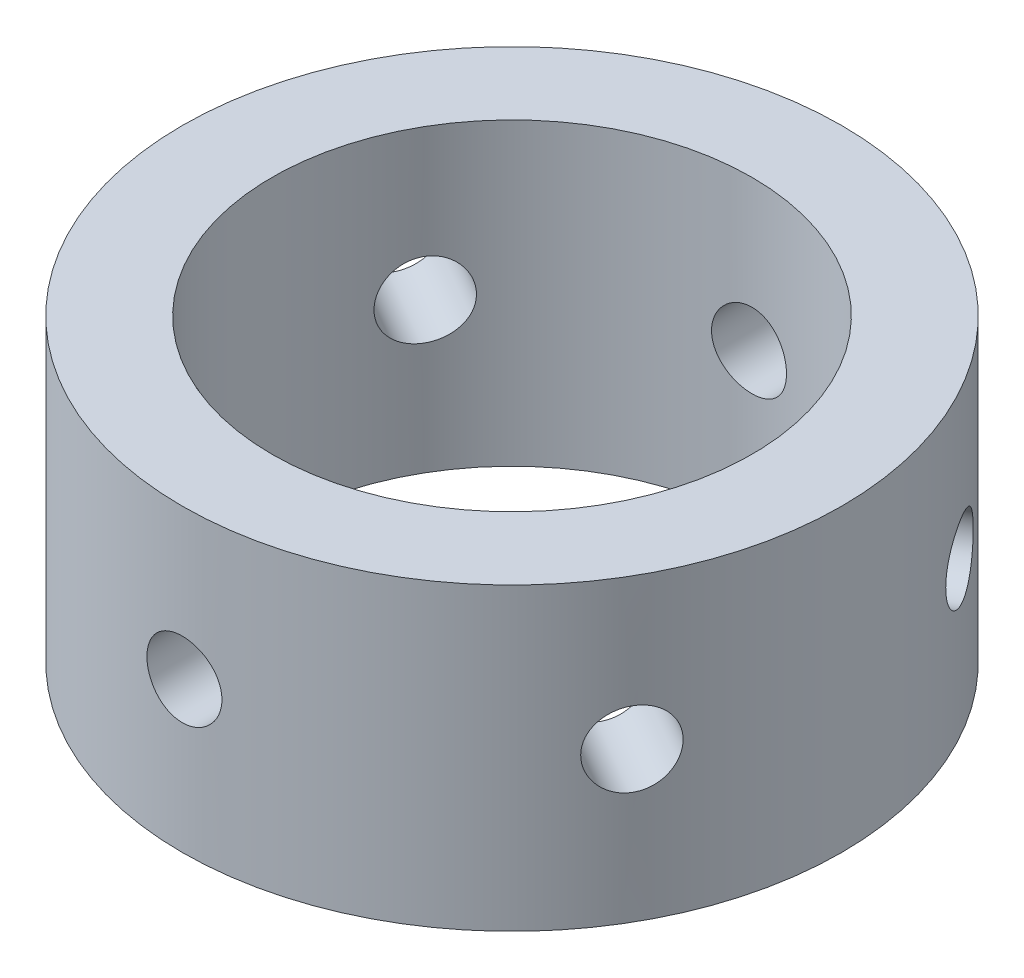
from build123d import *

# Parameters (mm, degrees)
SKETCH1_R                        = 34.8996
SKETCH1_R_2                      = 25.4
BOSS_EXTRUDE1_DEPTH              = 31.75
TAP_DRILL_FOR_3_8_16_TAP1_REACH  = 86.249
TAP_DRILL_FOR_3_8_16_TAP1_BORE_R = 3.96875
CIRPATTERN2_COUNT                = 6


with BuildPart() as part:
    # Sketch1 → Boss-Extrude1 (new body)
    with BuildSketch(Plane(origin=(0, 0, 0), x_dir=(1, 0, 0), z_dir=(0, 1, 0))):
        with Locations(Location((0, 0, 0), (0, 0, 270))):
            Circle(SKETCH1_R)
        with Locations(Location((0, 0, 0), (0, 0, 270))):
            Circle(SKETCH1_R_2, mode=Mode.SUBTRACT)
    extrude(amount=BOSS_EXTRUDE1_DEPTH)

    # Tap Drill for 3/8-16 Tap1 bore → Tap Drill for 3/8-16 Tap1 (cut, up to next)
    with BuildSketch(Plane.XY.offset(34.8996), mode=Mode.PRIVATE) as tap_drill_for_3_8_16_tap1_sk1:
        with Locations((0, 15.875)):
            Circle(TAP_DRILL_FOR_3_8_16_TAP1_BORE_R)
    tap_drill_for_3_8_16_tap1_tool1 = extrude(tap_drill_for_3_8_16_tap1_sk1.sketch, amount=-TAP_DRILL_FOR_3_8_16_TAP1_REACH, mode=Mode.PRIVATE) & part.part
    tap_drill_for_3_8_16_tap1 = tap_drill_for_3_8_16_tap1_tool1.solids().sort_by_distance((0, 15.875, 34.8996))[0]
    add(tap_drill_for_3_8_16_tap1, mode=Mode.SUBTRACT)

    # CirPattern2: Tap Drill for 3/8-16 Tap1 ×6 about axis
    cirpattern2_axis = Axis((0, 31.75, 0), (0, -1, 0))
    for i in range(1, CIRPATTERN2_COUNT):
        add(tap_drill_for_3_8_16_tap1.rotate(cirpattern2_axis, i * 360 / CIRPATTERN2_COUNT), mode=Mode.SUBTRACT)


solid = part.part
